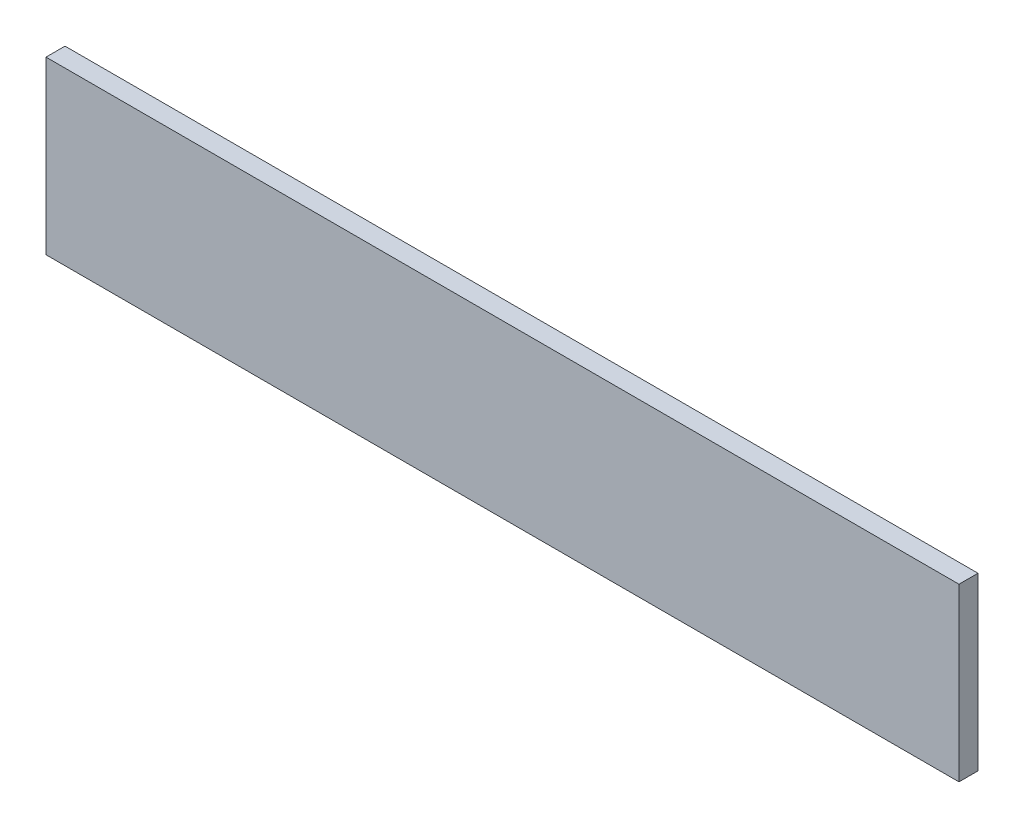
from build123d import *

# Parameters (mm, degrees)
SKETCH1_W           = 609.6
SKETCH1_H           = 114.3
BOSS_EXTRUDE1_DEPTH = 12.7


with BuildPart() as part:
    # Sketch1 → Boss-Extrude1 (new body)
    with BuildSketch(Plane.XY):
        Rectangle(SKETCH1_W, SKETCH1_H)
    extrude(amount=BOSS_EXTRUDE1_DEPTH)


solid = part.part
